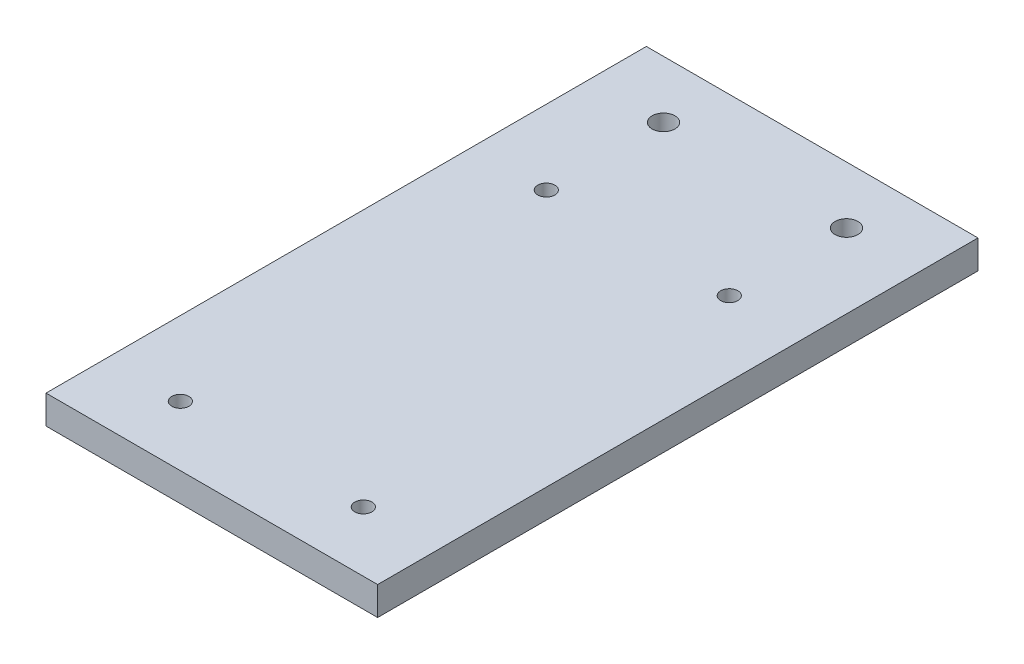
from build123d import *

# Parameters (mm, degrees)
SKETCH1_W           = 58
SKETCH1_H           = 105
SKETCH1_R           = 1.5
SKETCH1_R_2         = 2
BOSS_EXTRUDE1_DEPTH = 5


with BuildPart() as part:
    # Sketch1 → Boss-Extrude1 (new body)
    with BuildSketch(Plane(origin=(0, 0, 0), x_dir=(1, 0, 0), z_dir=(0, 1, 0))):
        Rectangle(SKETCH1_W, SKETCH1_H)
        with Locations((-16, 22)):
            Circle(SKETCH1_R, mode=Mode.SUBTRACT)
        with Locations((16, 22)):
            Circle(SKETCH1_R, mode=Mode.SUBTRACT)
        with Locations((16, -42)):
            Circle(SKETCH1_R, mode=Mode.SUBTRACT)
        with Locations((-16, -42)):
            Circle(SKETCH1_R, mode=Mode.SUBTRACT)
        with Locations((-16, 42.5)):
            Circle(SKETCH1_R_2, mode=Mode.SUBTRACT)
        with Locations((16, 42.5)):
            Circle(SKETCH1_R_2, mode=Mode.SUBTRACT)
    extrude(amount=BOSS_EXTRUDE1_DEPTH)


solid = part.part
